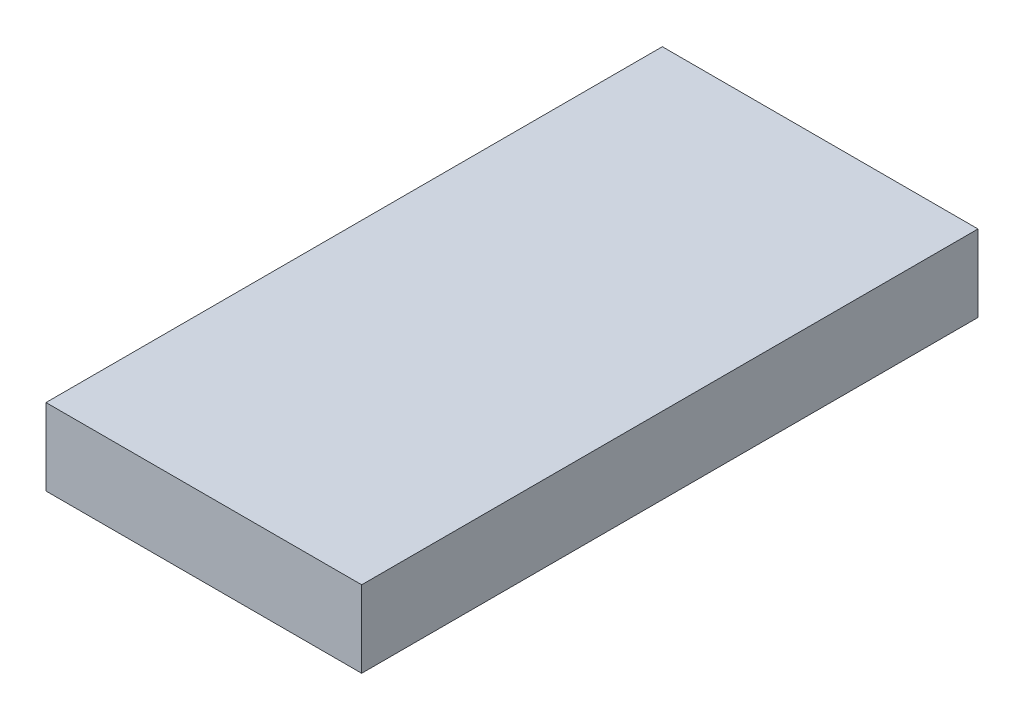
from build123d import *

# Parameters (mm, degrees)
SKETCH1_W           = 21
SKETCH1_H           = 41
BOSS_EXTRUDE1_DEPTH = 5.1


with BuildPart() as part:
    # Sketch1 → Boss-Extrude1 (new body)
    with BuildSketch(Plane(origin=(0, 0, 0), x_dir=(1, 0, 0), z_dir=(0, 1, 0))):
        Rectangle(SKETCH1_W, SKETCH1_H)
    extrude(amount=BOSS_EXTRUDE1_DEPTH)


solid = part.part
